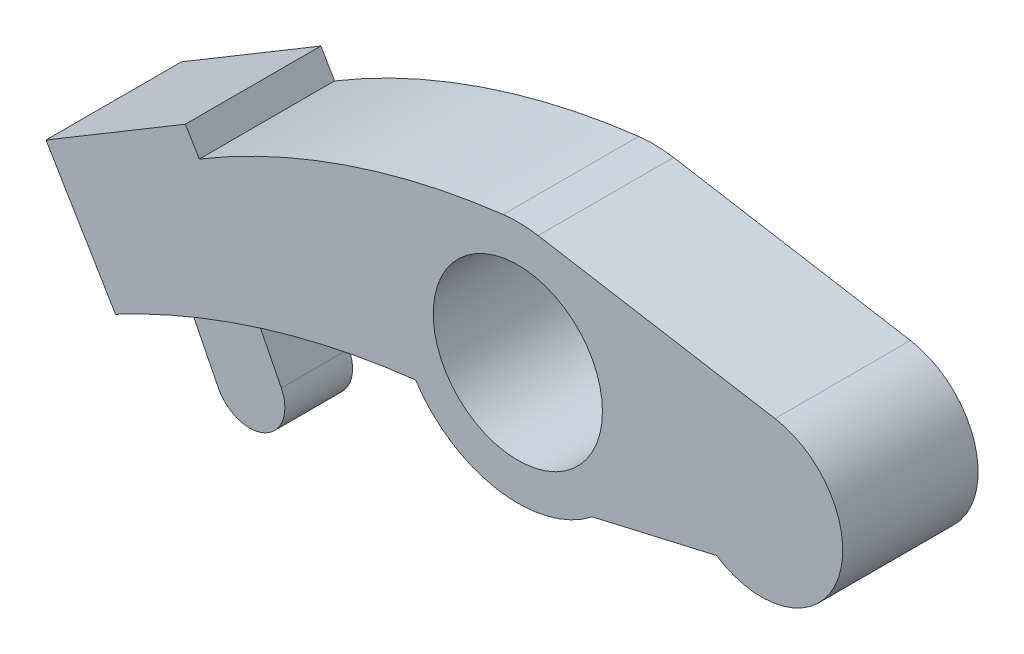
from build123d import *

# Parameters (mm, degrees)
SKETCH1_R           = 6.25
BOSS_EXTRUDE1_DEPTH = 5
BOSS_EXTRUDE2_DEPTH = 2.5


with BuildPart() as part:
    # Sketch1 → Boss-Extrude1 (new body, symmetric)
    with BuildSketch(Plane.XY):
        with BuildLine():
            ThreePointArc((14.68337521, -5), (23.5795956, -2.206380053), (19, 5.916079783))
            Line((19, 5.916079783), (1.5, 8.874119675))
            ThreePointArc((1.5, 8.874119675), (0.214418855, 8.997445446), (-1.075577539, 8.935498473))
            ThreePointArc((-1.075577539, 8.935498473), (-12.706895621, 6.277711403), (-23.530140222, 1.256877932))
            Line((-23.530140222, 1.256877932), (-24.557036845, 2.973118977))
            Line((-24.557036845, 2.973118977), (-34.854483116, -3.188260762))
            Line((-34.854483116, -3.188260762), (-29.72, -11.769465988))
            ThreePointArc((-29.72, -11.769465988), (-18.962777108, -7.283193101), (-7.556000741, -4.889463447))
            ThreePointArc((-7.556000741, -4.889463447), (-1.513896416, -8.871759557), (5.50692712, -7.118549971))
            Line((5.50692712, -7.118549971), (14.68337521, -5))
        make_face()
        Circle(SKETCH1_R, mode=Mode.SUBTRACT)
    extrude(amount=BOSS_EXTRUDE1_DEPTH, both=True)

    # Sketch2 → Boss-Extrude2 (add, symmetric)
    with BuildSketch(Plane.XY):
        with BuildLine():
            ThreePointArc((-22.221689741, -8.394920516), (-24.639151754, -9.353488219), (-27.014289175, -10.412590129))
            Line((-27.014289175, -10.412590129), (-24.649285993, -15.128581404))
            ThreePointArc((-24.649285993, -15.128581404), (-21.175329825, -16.33341689), (-19.970494339, -12.859460723))
            Line((-19.970494339, -12.859460723), (-22.221689741, -8.394920516))
        make_face()
    extrude(amount=BOSS_EXTRUDE2_DEPTH, both=True)


solid = part.part
